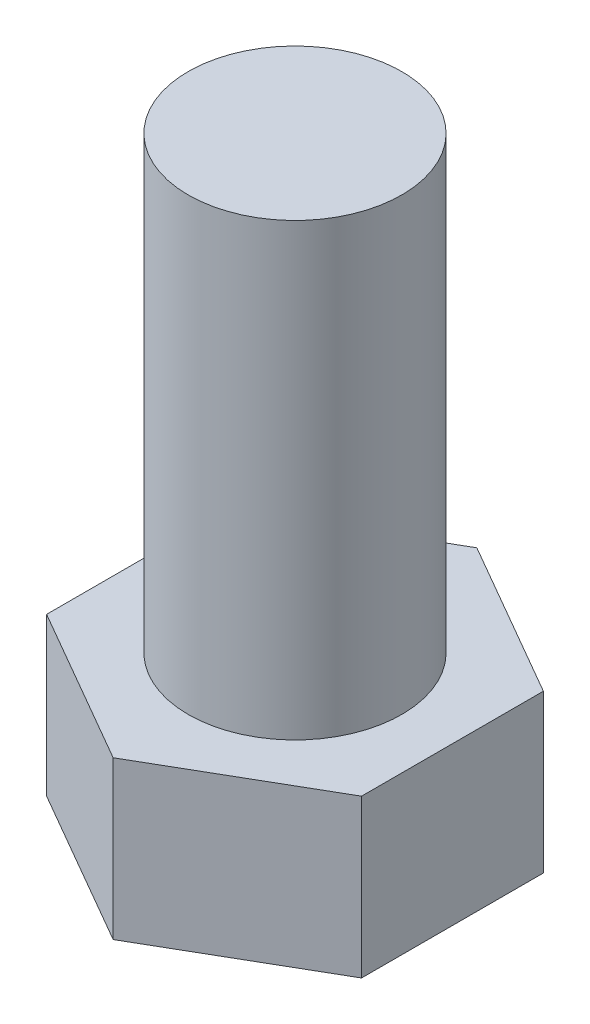
from build123d import *

# Parameters (mm, degrees)
BOSS_EXTRUDE1_DEPTH = 7
SKETCH2_R           = 4.75
BOSS_EXTRUDE2_DEPTH = 20


with BuildPart() as part:
    # Sketch1 → Boss-Extrude1 (new body)
    with BuildSketch(Plane(origin=(0, 0, 0), x_dir=(1, 0, 0), z_dir=(0, 1, 0))):
        Polygon((0, 8.082903769), (-7, 4.041451884), (-7, -4.041451884), (0, -8.082903769), (7, -4.041451884), (7, 4.041451884), align=None)
    extrude(amount=BOSS_EXTRUDE1_DEPTH)

    # Sketch2 → Boss-Extrude2 (add)
    with BuildSketch(Plane(origin=(0, 7, 0), x_dir=(1, 0, 0), z_dir=(0, 1, 0))):
        Circle(SKETCH2_R)
    extrude(amount=BOSS_EXTRUDE2_DEPTH)


solid = part.part
